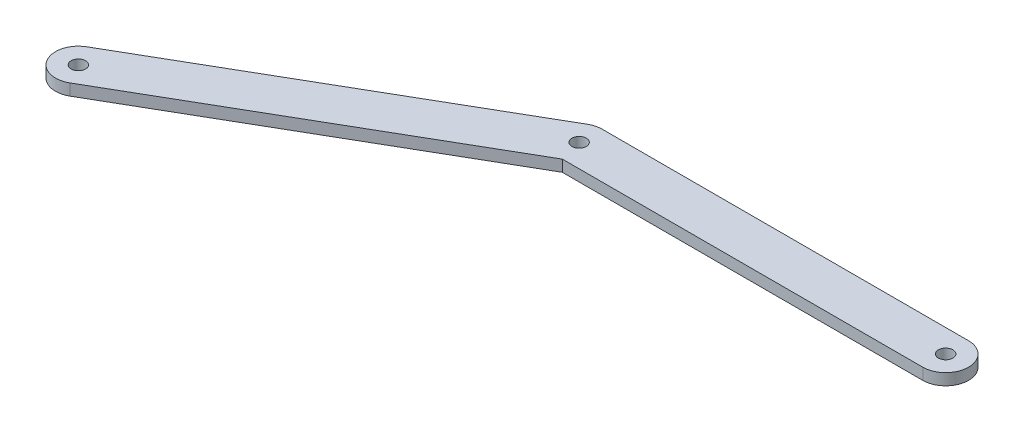
from build123d import *

# Parameters (mm, degrees)
SKETCH1_R               = 2.000000064
BOSS_EXTRUDE1_DEPTH     = 3.175
SKETCH2_R               = 2.000000064
BOSS_EXTRUDE2_DEPTH     = 3.175
SKETCH1_2_R             = 2.000000064
CUT_EXTRUDE4_DEPTH      = 3.81
CUT_EXTRUDE4_DEPTH_BACK = 3.81


with BuildPart() as part:
    # Sketch1 → Boss-Extrude1 (new body)
    with BuildSketch(Plane(origin=(0, 0, 0), x_dir=(1, 0, 0), z_dir=(0, 1, 0))):
        with BuildLine():
            Line((-50.8, 6.35), (50.8, 6.35))
            ThreePointArc((50.8, 6.35), (57.15, 0), (50.8, -6.35))
            Line((50.8, -6.35), (-50.8, -6.35))
            ThreePointArc((-50.8, -6.35), (-57.15, 0), (-50.8, 6.35))
        make_face()
        with Locations((-50.8, 0)):
            Circle(SKETCH1_R, mode=Mode.SUBTRACT)
        with Locations((50.8, 0)):
            Circle(SKETCH1_R, mode=Mode.SUBTRACT)
    extrude(amount=BOSS_EXTRUDE1_DEPTH)

    # Sketch2 → Boss-Extrude2 (add)
    with BuildSketch(Plane(origin=(0, 0, 0), x_dir=(1, 0, 0), z_dir=(0, 1, 0))):
        with BuildLine():
            Line((-141.963181024, -45.300738686), (-53.975, 5.499261314))
            ThreePointArc((-53.975, 5.499261314), (-45.300738686, 3.175), (-47.625, -5.499261314))
            Line((-47.625, -5.499261314), (-135.613181024, -56.299261314))
            ThreePointArc((-135.613181024, -56.299261314), (-144.287442339, -53.975), (-141.963181024, -45.300738686))
        make_face()
        with Locations((-138.788181024, -50.8)):
            Circle(SKETCH2_R, mode=Mode.SUBTRACT)
    extrude(amount=BOSS_EXTRUDE2_DEPTH)

    # Sketch1_2 → Cut-Extrude4 (cut, two sides)
    with BuildSketch(Plane(origin=(0, 0, 0), x_dir=(1, 0, 0), z_dir=(0, 1, 0))) as cut_extrude4_sk:
        with Locations((-50.8, 0)):
            Circle(SKETCH1_2_R)
    extrude(amount=CUT_EXTRUDE4_DEPTH, mode=Mode.SUBTRACT)
    extrude(cut_extrude4_sk.sketch, amount=-CUT_EXTRUDE4_DEPTH_BACK, mode=Mode.SUBTRACT)


solid = part.part
